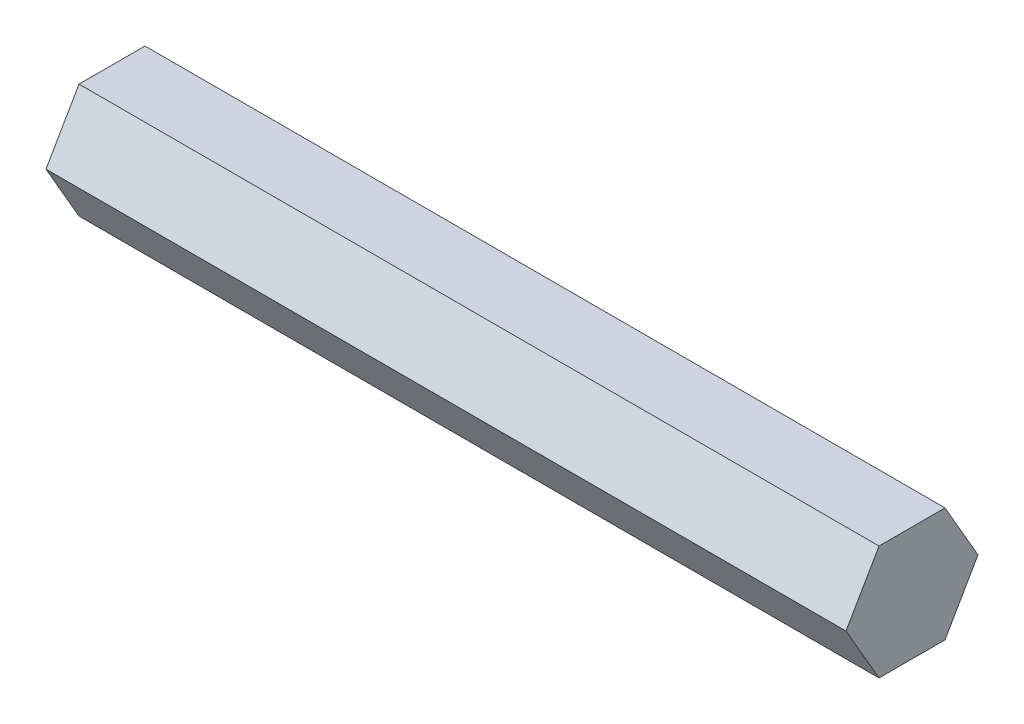
from build123d import *

# Parameters (mm, degrees)
BOSS_EXTRUDE1_DEPTH = 88.9


with BuildPart() as part:
    # Sketch1 → Boss-Extrude1 (new body)
    with BuildSketch(Plane(origin=(0, 0, 0), x_dir=(0, 0, -1), z_dir=(1, 0, 0))):
        Polygon((-7.332348419, 0), (-3.666174209, -6.35), (3.666174209, -6.35), (7.332348419, 0), (3.666174209, 6.35), (-3.666174209, 6.35), align=None)
    extrude(amount=BOSS_EXTRUDE1_DEPTH)


solid = part.part
